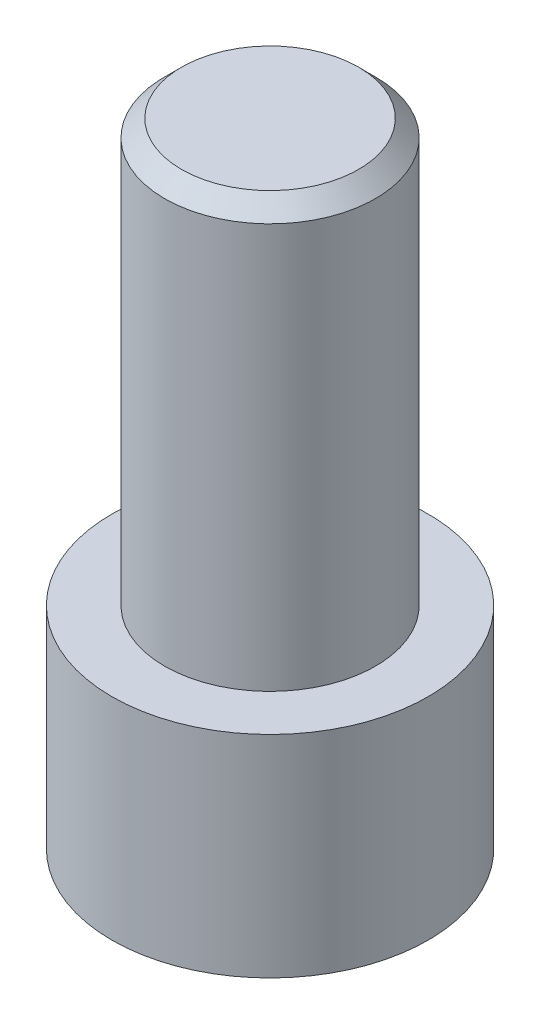
from build123d import *

# Parameters (mm, degrees)
SKETCH1_R           = 4.7625
BOSS_EXTRUDE1_DEPTH = 6.35
SKETCH2_R           = 3.175
BOSS_EXTRUDE2_DEPTH = 12.7
CHAMFER1_SIZE       = 0.508
CUT_EXTRUDE1_DEPTH  = 3.81


with BuildPart() as part:
    # Sketch1 → Boss-Extrude1 (new body)
    with BuildSketch(Plane(origin=(0, 0, 0), x_dir=(1, 0, 0), z_dir=(0, 1, 0))):
        Circle(SKETCH1_R)
    extrude(amount=BOSS_EXTRUDE1_DEPTH)

    # Sketch2 → Boss-Extrude2 (add)
    with BuildSketch(Plane(origin=(0, 6.35, 0), x_dir=(1, 0, 0), z_dir=(0, 1, 0))):
        Circle(SKETCH2_R)
    extrude(amount=BOSS_EXTRUDE2_DEPTH)

    # Chamfer1
    chamfer1_edges = [part.edges().sort_by_distance(p)[0] for p in [
        (-3.175, 19.05, 0),
    ]]
    chamfer(chamfer1_edges, length=CHAMFER1_SIZE)

    # Sketch3 → Cut-Extrude1 (cut)
    with BuildSketch(Plane.XZ):
        Polygon((1.27, 2.199704526), (-1.27, 2.199704526), (-2.54, 0), (-1.27, -2.199704526), (1.27, -2.199704526), (2.54, 0), align=None)
    extrude(amount=-CUT_EXTRUDE1_DEPTH, mode=Mode.SUBTRACT)


solid = part.part
